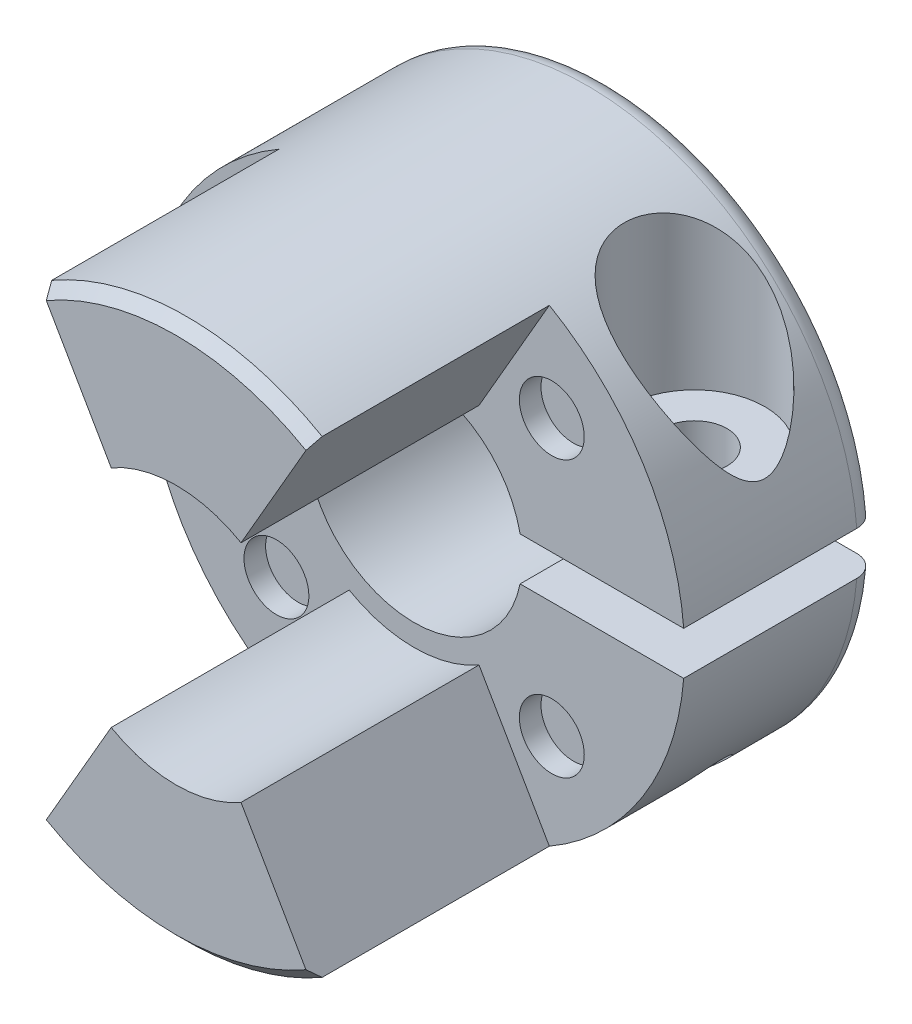
from build123d import *

# Parameters (mm, degrees)
ESBO_O1_R                 = 12.5
RESSALTO_EXTRUS_O1_DEPTH  = 20
CORTE_EXTRUS_O3_DEPTH     = 11
ESBO_O3_R                 = 5
CORTE_EXTRUS_O4_DEPTH     = 21
ESBO_O6_W                 = 12
ESBO_O6_H                 = 2
CORTE_EXTRUS_O5_DEPTH     = 10
CORTE_EXTRUS_O6_START     = -3
ESBO_O7_R                 = 3.25
CORTE_EXTRUS_O6_DEPTH     = 9.5
FURO_ROSCADO_DE_M3X0_51_D = 2.5
FILETE1_R                 = 1
ESBO_O10_R                = 1.5
CORTE_EXTRUS_O7_DEPTH     = 1
CHANFRO1_SIZE             = 0.5
CORTE_EXTRUS_O8_REACH     = 18.5
ESBO_O11_R                = 1.5
ESBO_O12_R                = 6
CORTE_EXTRUS_O9_DEPTH     = 11
PADR_OCIRCULAR1_COUNT     = 4
CHANFRO2_SIZE             = 0.5


with BuildPart() as part:
    # Esboço1 → Ressalto-extrusão1 (new body)
    with BuildSketch(Plane.XY):
        Circle(ESBO_O1_R)
    extrude(amount=RESSALTO_EXTRUS_O1_DEPTH)

    # Esboço2 → Corte-extrusão3 (cut)
    with BuildSketch(Plane.XY.offset(20)):
        with BuildLine():
            Line((0, 0), (6.25, 10.825317547))
            ThreePointArc((6.25, 10.825317547), (12.5, 0), (6.25, -10.825317547))
            Line((6.25, -10.825317547), (0, 0))
        make_face()
    corte_extrus_o3 = extrude(amount=-CORTE_EXTRUS_O3_DEPTH, mode=Mode.SUBTRACT)

    # Esboço3 → Corte-extrusão4 (cut, through all)
    with BuildSketch(Plane(origin=(0, 0, 0), x_dir=(-1, 0, 0), z_dir=(0, 0, -1))):
        Circle(ESBO_O3_R)
    extrude(amount=-CORTE_EXTRUS_O4_DEPTH, mode=Mode.SUBTRACT)

    # Espelhar1: Corte-extrusão3 across plane
    add(corte_extrus_o3.mirror(Plane(origin=(0, 0, 0), x_dir=(0, 0, 1), z_dir=(1, 0, 0))), mode=Mode.SUBTRACT)

    # Esboço6 → Corte-extrusão5 (cut, through all)
    with BuildSketch(Plane.XY.offset(9)):
        with Locations((7, 0)):
            Rectangle(ESBO_O6_W, ESBO_O6_H)
    extrude(amount=-CORTE_EXTRUS_O5_DEPTH, mode=Mode.SUBTRACT)

    # Esboço7 → Corte-extrusão6 (cut, through all)
    with BuildSketch(Plane.XZ.offset(-1).offset(CORTE_EXTRUS_O6_START)):
        with Locations((8.459935794, 4.5)):
            Circle(ESBO_O7_R)
    extrude(amount=-CORTE_EXTRUS_O6_DEPTH, mode=Mode.SUBTRACT)

    # Furo roscado de M3x0.51 (through all)
    with Locations(Plane(origin=(0, 4, 0), x_dir=(1, 0, 0), z_dir=(0, 1, 0))):
        with Locations((8.459935794, -4.5)):
            Hole(FURO_ROSCADO_DE_M3X0_51_D / 2)

    # Filete1
    filete1_edges = [part.edges().sort_by_distance(p)[0] for p in [
        (-12.5, 0, 0),
    ]]
    fillet(filete1_edges, radius=FILETE1_R)

    # Esboço10 → Corte-extrusão7 (cut)
    with BuildSketch(Plane.XY.offset(9)):
        with Locations((6.363961031, -6.363961031)):
            Circle(ESBO_O10_R)
    corte_extrus_o7 = extrude(amount=-CORTE_EXTRUS_O7_DEPTH, mode=Mode.SUBTRACT)

    # Chanfro1
    chanfro1_edges = [part.edges().sort_by_distance(p)[0] for p in [
        (0, -12.5, 20),
        (0, 12.5, 20),
    ]]
    chamfer(chanfro1_edges, length=CHANFRO1_SIZE)

    # Esboço11 → Corte-extrusão8 (cut, up to next)
    with BuildSketch(Plane(origin=(0, 4, 0), x_dir=(1, 0, 0), z_dir=(0, 1, 0)), mode=Mode.PRIVATE) as corte_extrus_o8_sk1:
        with Locations((8.459935794, -4.5)):
            Circle(ESBO_O11_R)
    corte_extrus_o8_tool1 = extrude(corte_extrus_o8_sk1.sketch, amount=-CORTE_EXTRUS_O8_REACH, mode=Mode.PRIVATE) & part.part
    add(corte_extrus_o8_tool1.solids().sort_by_distance((8.459936, 4, 4.5))[0], mode=Mode.SUBTRACT)

    # Esboço12 → Corte-extrusão9 (cut)
    with BuildSketch(Plane.XY.offset(20)):
        Circle(ESBO_O12_R)
    extrude(amount=-CORTE_EXTRUS_O9_DEPTH, mode=Mode.SUBTRACT)

    # PadrãoCircular1: Corte-extrusão7 ×4 about axis
    padr_ocircular1_axis = Axis((0, 0, 0), (0, 0, 1))
    for i in range(1, PADR_OCIRCULAR1_COUNT):
        add(corte_extrus_o7.rotate(padr_ocircular1_axis, i * 360 / PADR_OCIRCULAR1_COUNT), mode=Mode.SUBTRACT)

    # Chanfro2
    chanfro2_edges = [part.edges().sort_by_distance(p)[0] for p in [
        (-5, 0, 0),
    ]]
    chamfer(chanfro2_edges, length=CHANFRO2_SIZE)


solid = part.part
